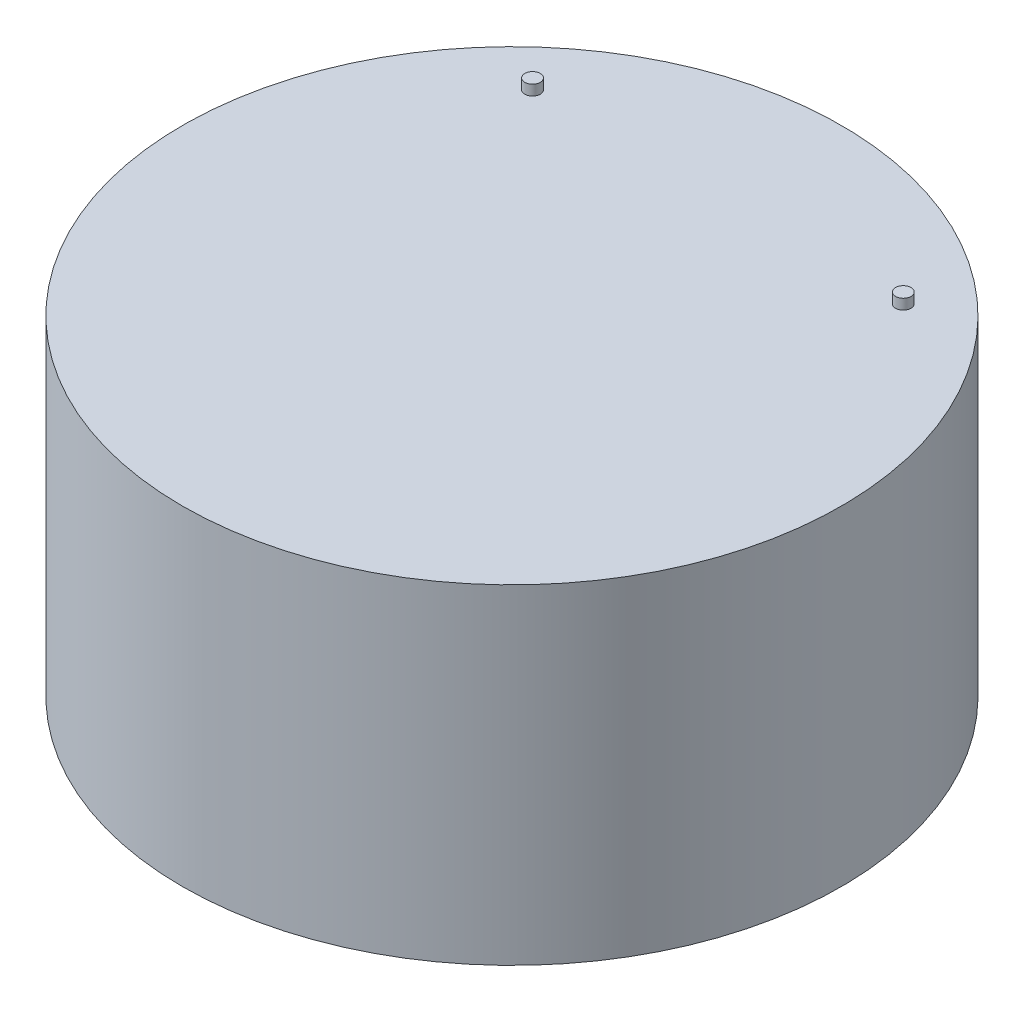
from build123d import *

# Parameters (mm, degrees)
SKETCH1_R           = 50.8
BOSS_EXTRUDE1_DEPTH = 50.8
SKETCH3_R           = 1.190625
BOSS_EXTRUDE3_DEPTH = 1.588262


with BuildPart() as part:
    # Sketch1 → Boss-Extrude1 (new body)
    with BuildSketch(Plane(origin=(0, 0, 0), x_dir=(1, 0, 0), z_dir=(0, 1, 0))):
        Circle(SKETCH1_R)
    extrude(amount=BOSS_EXTRUDE1_DEPTH)

    # Sketch3 → Boss-Extrude3 (add)
    with BuildSketch(Plane(origin=(0, 50.8, 0), x_dir=(1, 0, 0), z_dir=(0, 1, 0))):
        with Locations((28.575, 31.75)):
            Circle(SKETCH3_R)
        with Locations((-28.575, 31.75)):
            Circle(SKETCH3_R)
    extrude(amount=BOSS_EXTRUDE3_DEPTH)


solid = part.part
